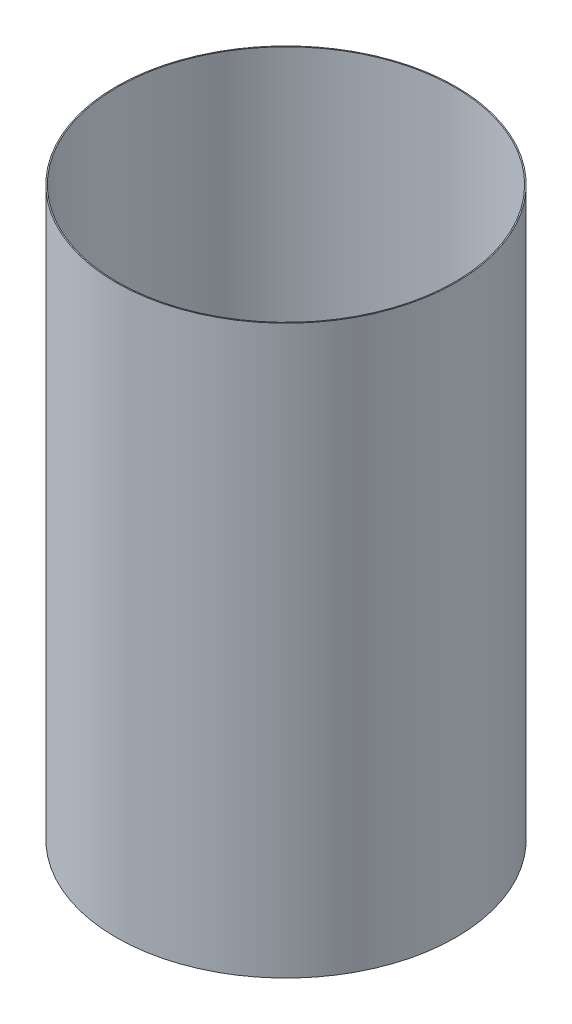
from build123d import *

# Parameters (mm, degrees)
SKETCH1_W = 0.254
SKETCH1_H = 133.35


with BuildPart() as part:
    # Sketch1 → Revolve-Thin1 (revolve)
    with BuildSketch(Plane.XY):
        with Locations((-39.80815, -135.67819341)):
            Rectangle(SKETCH1_W, SKETCH1_H)
    revolve(axis=Axis((0, 55, 0), (0, -1, 0)))


solid = part.part
